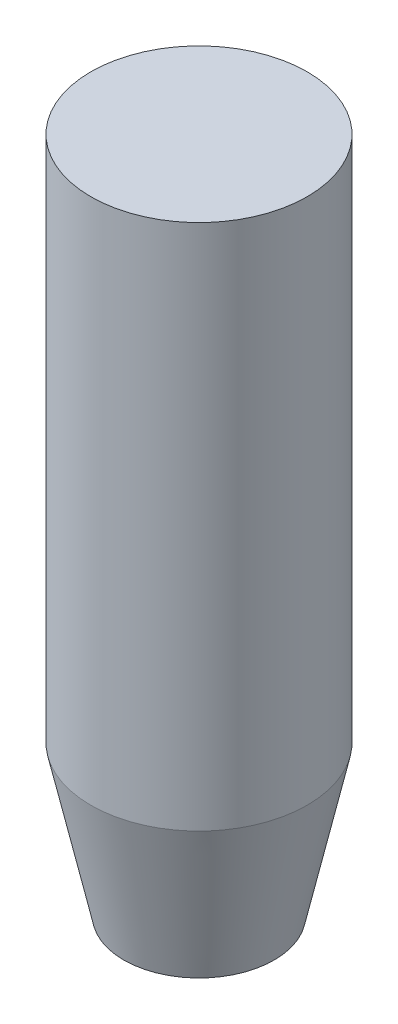
from build123d import *

# Parameters (mm, degrees)
SKETCH1_R           = 18.25625
BOSS_EXTRUDE1_DEPTH = 114.3
CHAMFER1_SIZE       = 5.55625
CHAMFER1_SIZE2      = 25.4


with BuildPart() as part:
    # Sketch1 → Boss-Extrude1 (new body)
    with BuildSketch(Plane(origin=(0, 0, 0), x_dir=(1, 0, 0), z_dir=(0, 1, 0))):
        Circle(SKETCH1_R)
    extrude(amount=BOSS_EXTRUDE1_DEPTH)

    # Chamfer1
    chamfer1_edges = [part.edges().sort_by_distance(p)[0] for p in [
        (-18.25625, 0, 0),
    ]]
    chamfer1_side = [part.faces().sort_by_distance(p)[0] for p in [
        (0, 0, 0),
    ]]
    chamfer(chamfer1_edges, length=CHAMFER1_SIZE, length2=CHAMFER1_SIZE2, reference=chamfer1_side[0])


solid = part.part
